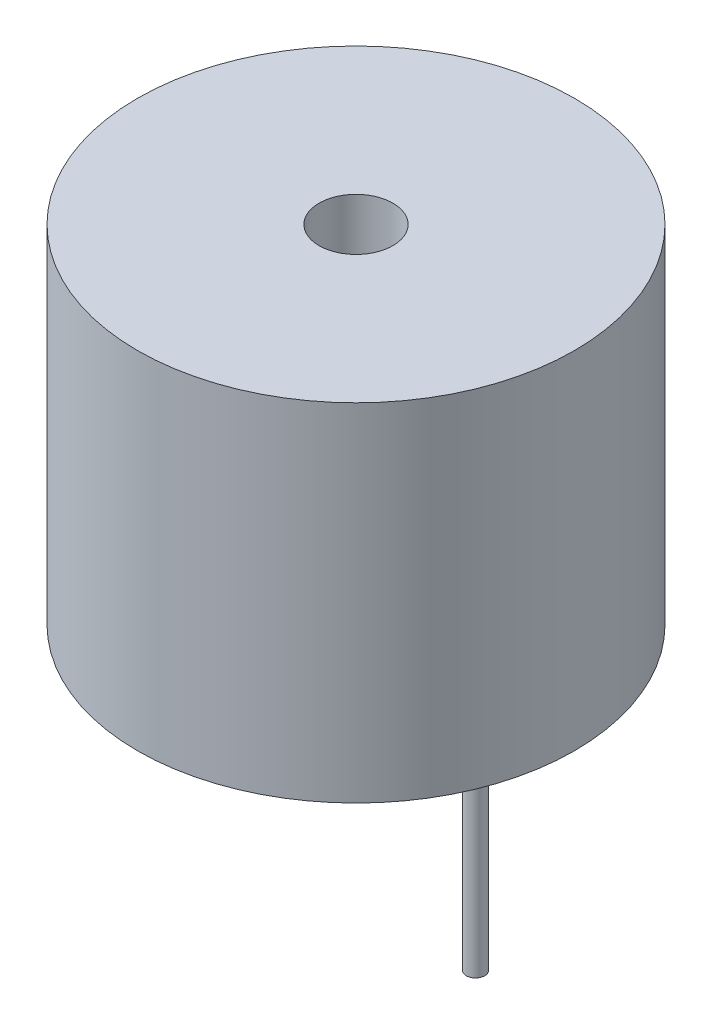
from build123d import *

# Parameters (mm, degrees)
CROQUIS1_R              = 5.925
SALIENTE_EXTRUIR1_DEPTH = 9.4
CROQUIS2_R              = 0.25
SALIENTE_EXTRUIR2_DEPTH = 4.9
CROQUIS3_R              = 0.25
SALIENTE_EXTRUIR3_DEPTH = 6.5
CROQUIS4_R              = 1
CORTAR_EXTRUIR1_DEPTH   = 4.5


with BuildPart() as part:
    # Croquis1 → Saliente-Extruir1 (new body)
    with BuildSketch(Plane(origin=(0, 0, 0), x_dir=(1, 0, 0), z_dir=(0, 1, 0))):
        Circle(CROQUIS1_R)
    extrude(amount=SALIENTE_EXTRUIR1_DEPTH)

    # Croquis2 → Saliente-Extruir2 (add)
    with BuildSketch(Plane.XZ):
        with Locations((-3.241786254, 0)):
            Circle(CROQUIS2_R)
    extrude(amount=SALIENTE_EXTRUIR2_DEPTH)

    # Croquis3 → Saliente-Extruir3 (add)
    with BuildSketch(Plane.XZ):
        with Locations((3.241786254, 0)):
            Circle(CROQUIS3_R)
    extrude(amount=SALIENTE_EXTRUIR3_DEPTH)

    # Croquis4 → Cortar-Extruir1 (cut)
    with BuildSketch(Plane(origin=(0, 9.4, 0), x_dir=(1, 0, 0), z_dir=(0, 1, 0))):
        Circle(CROQUIS4_R)
    extrude(amount=-CORTAR_EXTRUIR1_DEPTH, mode=Mode.SUBTRACT)


solid = part.part
